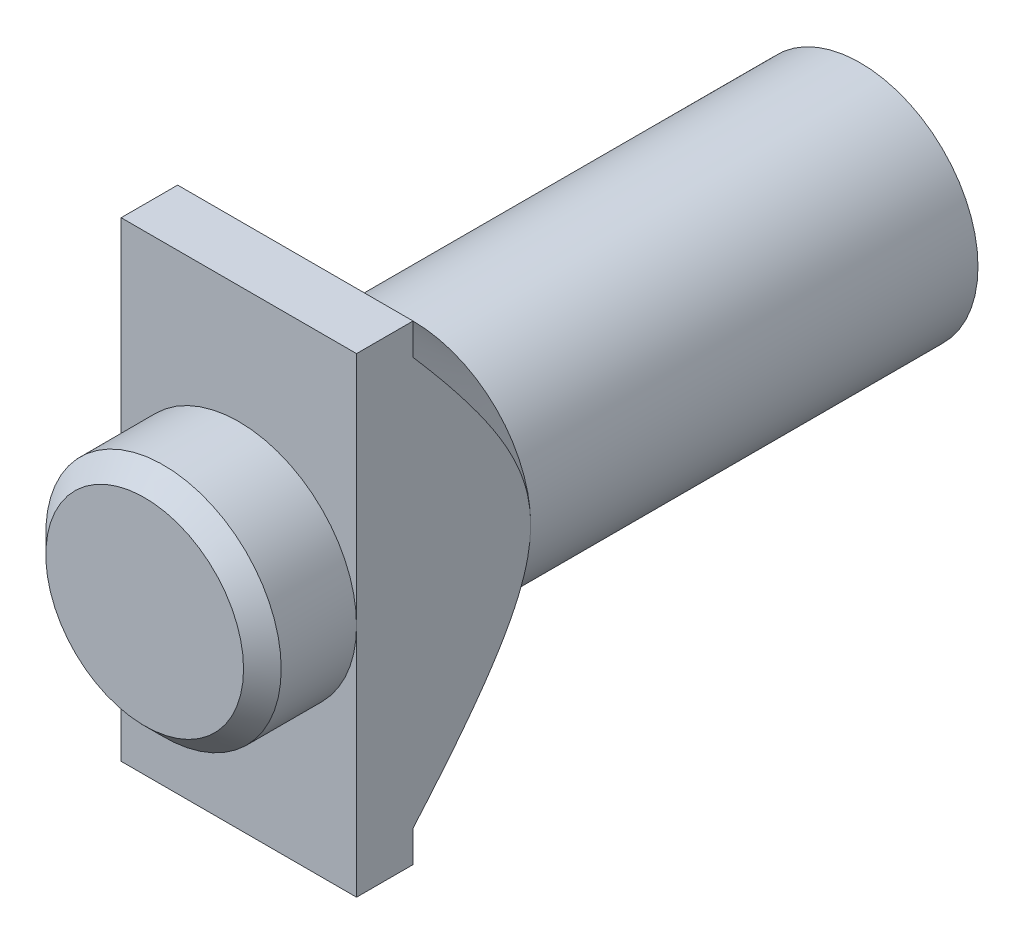
from build123d import *

# Parameters (mm, degrees)
SKETCH1_R           = 6.25
BOSS_EXTRUDE1_DEPTH = 30
CUT_EXTRUDE3_DEPTH  = 15
SKETCH9_W           = 12.5
SKETCH9_H           = 25
BOSS_EXTRUDE2_DEPTH = 3
SKETCH11_W          = 10.933781676
SKETCH11_H          = 25
SKETCH11_W_2        = 11.938681189
CUT_EXTRUDE4_DEPTH  = 34
SKETCH12_R          = 6.25
BOSS_EXTRUDE3_DEPTH = 5
CHAMFER1_SIZE       = 1


with BuildPart() as part:
    # Sketch1 → Boss-Extrude1 (new body)
    with BuildSketch(Plane.XY):
        Circle(SKETCH1_R)
    extrude(amount=BOSS_EXTRUDE1_DEPTH)

    # Sketch8 → Cut-Extrude3 (cut)
    with BuildSketch(Plane(origin=(0, 0, 0), x_dir=(-1, 0, 0), z_dir=(0, 0, -1))):
        with BuildLine():
            Line((-1.616322988, 2.1), (1.616322988, 2.1))
            ThreePointArc((1.616322988, 2.1), (0, -2.65), (-1.616322988, 2.1))
        make_face()
    extrude(amount=-CUT_EXTRUDE3_DEPTH, mode=Mode.SUBTRACT)

    # Sketch9 → Boss-Extrude2 (add)
    with BuildSketch(Plane.XY.offset(30)):
        Rectangle(SKETCH9_W, SKETCH9_H)
    extrude(amount=BOSS_EXTRUDE2_DEPTH)

    # Sketch10 → Revolve1 (revolve)
    with BuildSketch(Plane(origin=(0, 0, 0), x_dir=(0, 0, -1), z_dir=(1, 0, 0))):
        Polygon((-30, 12.5), (-30, 0), (-17.5, 0), align=None)
    revolve(axis=Axis((0, 0, 63.541170981), (0, 0, 1)))

    # Sketch11 → Cut-Extrude4 (cut, through all)
    with BuildSketch(Plane.XY.offset(33)):
        with Locations((-11.716890838, 0)):
            Rectangle(SKETCH11_W, SKETCH11_H)
        with Locations((12.219340595, 0)):
            Rectangle(SKETCH11_W_2, SKETCH11_H)
    extrude(amount=-CUT_EXTRUDE4_DEPTH, mode=Mode.SUBTRACT)

    # Sketch12 → Boss-Extrude3 (add)
    with BuildSketch(Plane.XY.offset(33)):
        Circle(SKETCH12_R)
    extrude(amount=BOSS_EXTRUDE3_DEPTH)

    # Chamfer1
    chamfer1_edges = [part.edges().sort_by_distance(p)[0] for p in [
        (-6.25, 0, 38),
    ]]
    chamfer(chamfer1_edges, length=CHAMFER1_SIZE)


solid = part.part
